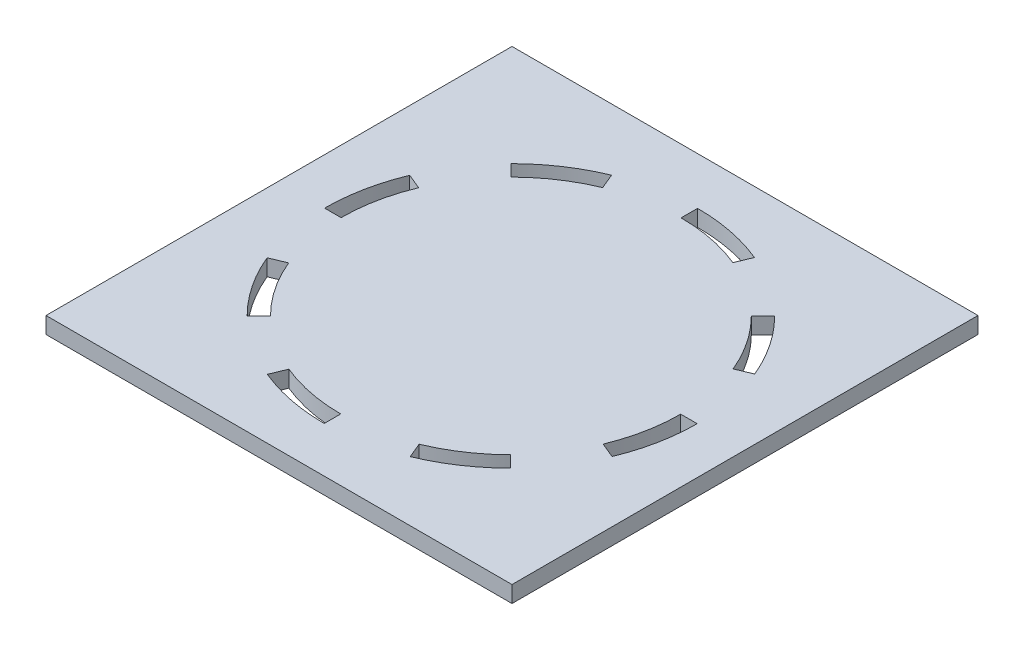
from build123d import *

# Parameters (mm, degrees)
SKETCH1_W           = 143.51
SKETCH1_H           = 143.51
BOSS_EXTRUDE1_DEPTH = 5.08
CUT_EXTRUDE1_DEPTH  = 6.08
CIRPATTERN1_COUNT   = 8


with BuildPart() as part:
    # Sketch1 → Boss-Extrude1 (new body)
    with BuildSketch(Plane(origin=(0, 0, 0), x_dir=(1, 0, 0), z_dir=(0, 1, 0))):
        with Locations((71.755, 71.755)):
            Rectangle(SKETCH1_W, SKETCH1_H)
    extrude(amount=BOSS_EXTRUDE1_DEPTH)

    # Sketch3 → Cut-Extrude1 (cut, through all)
    with BuildSketch(Plane(origin=(0, 5.08, 0), x_dir=(1, 0, 0), z_dir=(0, 1, 0))):
        with BuildLine():
            Line((71.755, 128.905), (71.755, 123.825))
            ThreePointArc((71.755, 123.825), (81.913353067, 122.824489551), (91.681326323, 119.861407258))
            Line((91.681326323, 119.861407258), (93.62535816, 124.554715283))
            ThreePointArc((93.62535816, 124.554715283), (82.904411903, 127.806878775), (71.755, 128.905))
        make_face()
    cut_extrude1 = extrude(amount=-CUT_EXTRUDE1_DEPTH, mode=Mode.SUBTRACT)

    # CirPattern1: Cut-Extrude1 ×8 about axis
    cirpattern1_axis = Axis((71.698667162, 0, -71.471795698), (0, 1, 0))
    for i in range(1, CIRPATTERN1_COUNT):
        add(cut_extrude1.rotate(cirpattern1_axis, i * 360 / CIRPATTERN1_COUNT), mode=Mode.SUBTRACT)


solid = part.part
